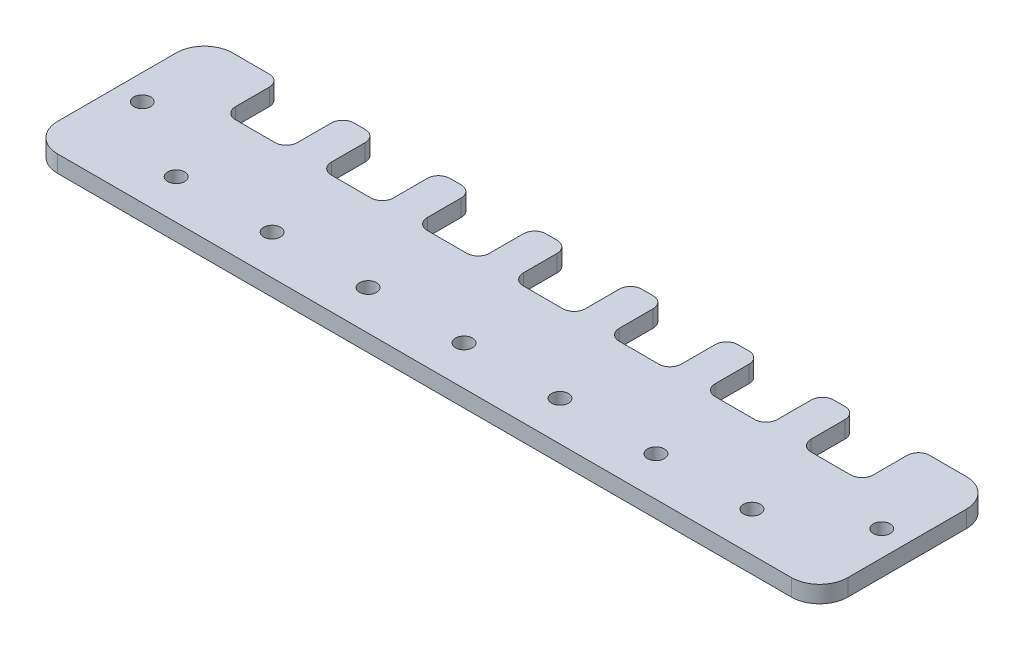
from build123d import *

# Parameters (mm, degrees)
SKETCH1_R           = 1.5
BOSS_EXTRUDE1_DEPTH = 3


with BuildPart() as part:
    # Sketch1 → Boss-Extrude1 (new body)
    with BuildSketch(Plane(origin=(0, 0, 0), x_dir=(1, 0, 0), z_dir=(0, 1, 0))):
        with BuildLine():
            Line((65, 15.5), (58.5, 15.5))
            ThreePointArc((58.5, 15.5), (57.085786438, 14.914213562), (56.5, 13.5))
            Line((56.5, 13.5), (56.5, 7.5))
            ThreePointArc((56.5, 7.5), (55.914213562, 6.085786438), (54.5, 5.5))
            Line((54.5, 5.5), (47.5, 5.5))
            ThreePointArc((47.5, 5.5), (46.085786438, 6.085786438), (45.5, 7.5))
            Line((45.5, 7.5), (45.5, 13.5))
            ThreePointArc((45.5, 13.5), (44.914213562, 14.914213562), (43.5, 15.5))
            Line((43.5, 15.5), (41.5, 15.5))
            ThreePointArc((41.5, 15.5), (40.085786438, 14.914213562), (39.5, 13.5))
            Line((39.5, 13.5), (39.5, 7.5))
            ThreePointArc((39.5, 7.5), (38.914213562, 6.085786438), (37.5, 5.5))
            Line((37.5, 5.5), (30.5, 5.5))
            ThreePointArc((30.5, 5.5), (29.085786438, 6.085786438), (28.5, 7.5))
            Line((28.5, 7.5), (28.5, 13.5))
            ThreePointArc((28.5, 13.5), (27.914213562, 14.914213562), (26.5, 15.5))
            Line((26.5, 15.5), (24.5, 15.5))
            ThreePointArc((24.5, 15.5), (23.085786438, 14.914213562), (22.5, 13.5))
            Line((22.5, 13.5), (22.5, 7.5))
            ThreePointArc((22.5, 7.5), (21.914213562, 6.085786438), (20.5, 5.5))
            Line((20.5, 5.5), (13.5, 5.5))
            ThreePointArc((13.5, 5.5), (12.085786438, 6.085786438), (11.5, 7.5))
            Line((11.5, 7.5), (11.5, 13.5))
            ThreePointArc((11.5, 13.5), (10.914213562, 14.914213562), (9.5, 15.5))
            Line((9.5, 15.5), (7.5, 15.5))
            ThreePointArc((7.5, 15.5), (6.085786438, 14.914213562), (5.5, 13.5))
            Line((5.5, 13.5), (5.5, 7.5))
            ThreePointArc((5.5, 7.5), (4.914213562, 6.085786438), (3.5, 5.5))
            Line((3.5, 5.5), (-3.5, 5.5))
            ThreePointArc((-3.5, 5.5), (-4.914213562, 6.085786438), (-5.5, 7.5))
            Line((-5.5, 7.5), (-5.5, 13.5))
            ThreePointArc((-5.5, 13.5), (-6.085786438, 14.914213562), (-7.5, 15.5))
            Line((-7.5, 15.5), (-9.5, 15.5))
            ThreePointArc((-9.5, 15.5), (-10.914213562, 14.914213562), (-11.5, 13.5))
            Line((-11.5, 13.5), (-11.5, 7.5))
            ThreePointArc((-11.5, 7.5), (-12.085786438, 6.085786438), (-13.5, 5.5))
            Line((-13.5, 5.5), (-20.5, 5.5))
            ThreePointArc((-20.5, 5.5), (-21.914213562, 6.085786438), (-22.5, 7.5))
            Line((-22.5, 7.5), (-22.5, 13.5))
            ThreePointArc((-22.5, 13.5), (-23.085786438, 14.914213562), (-24.5, 15.5))
            Line((-24.5, 15.5), (-26.5, 15.5))
            ThreePointArc((-26.5, 15.5), (-27.914213562, 14.914213562), (-28.5, 13.5))
            Line((-28.5, 13.5), (-28.5, 7.5))
            ThreePointArc((-28.5, 7.5), (-29.085786438, 6.085786438), (-30.5, 5.5))
            Line((-30.5, 5.5), (-37.5, 5.5))
            ThreePointArc((-37.5, 5.5), (-38.914213562, 6.085786438), (-39.5, 7.5))
            Line((-39.5, 7.5), (-39.5, 13.5))
            ThreePointArc((-39.5, 13.5), (-40.085786438, 14.914213562), (-41.5, 15.5))
            Line((-41.5, 15.5), (-43.5, 15.5))
            ThreePointArc((-43.5, 15.5), (-44.914213562, 14.914213562), (-45.5, 13.5))
            Line((-45.5, 13.5), (-45.5, 7.5))
            ThreePointArc((-45.5, 7.5), (-46.085786438, 6.085786438), (-47.5, 5.5))
            Line((-47.5, 5.5), (-54.5, 5.5))
            ThreePointArc((-54.5, 5.5), (-55.914213562, 6.085786438), (-56.5, 7.5))
            Line((-56.5, 7.5), (-56.5, 13.5))
            ThreePointArc((-56.5, 13.5), (-57.085786438, 14.914213562), (-58.5, 15.5))
            Line((-58.5, 15.5), (-65, 15.5))
            ThreePointArc((-65, 15.5), (-68.535533906, 14.035533906), (-70, 10.5))
            Line((-70, 10.5), (-70, -10.5))
            ThreePointArc((-70, -10.5), (-68.535533906, -14.035533906), (-65, -15.5))
            Line((-65, -15.5), (65, -15.5))
            ThreePointArc((65, -15.5), (68.535533906, -14.035533906), (70, -10.5))
            Line((70, -10.5), (70, 10.5))
            ThreePointArc((70, 10.5), (68.535533906, 14.035533906), (65, 15.5))
        make_face()
        with Locations((-65.5, 0)):
            Circle(SKETCH1_R, mode=Mode.SUBTRACT)
        with Locations((65.5, 0)):
            Circle(SKETCH1_R, mode=Mode.SUBTRACT)
        with Locations((-51, -8.5)):
            Circle(SKETCH1_R, mode=Mode.SUBTRACT)
        with Locations((-34, -8.5)):
            Circle(SKETCH1_R, mode=Mode.SUBTRACT)
        with Locations((-17, -8.5)):
            Circle(SKETCH1_R, mode=Mode.SUBTRACT)
        with Locations((0, -8.5)):
            Circle(SKETCH1_R, mode=Mode.SUBTRACT)
        with Locations((17, -8.5)):
            Circle(SKETCH1_R, mode=Mode.SUBTRACT)
        with Locations((34, -8.5)):
            Circle(SKETCH1_R, mode=Mode.SUBTRACT)
        with Locations((51, -8.5)):
            Circle(SKETCH1_R, mode=Mode.SUBTRACT)
    extrude(amount=BOSS_EXTRUDE1_DEPTH)


solid = part.part
